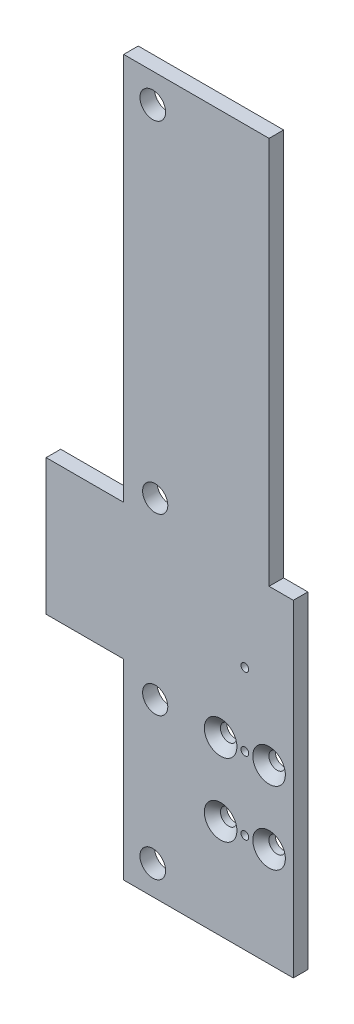
from build123d import *

# Parameters (mm, degrees)
SKETCH1_W                                    = 20
SKETCH1_H                                    = 40
BOSS_EXTRUDE1_DEPTH                          = 3
CSK_FOR_M3_HEX_SOCKET_COUNTERSUNK_CA_2_COUNT = 2
CSK_FOR_M3_HEX_SOCKET_COUNTERSUNK_CA_2_PITCH = 10
CSK_FOR_M3_HEX_SOCKET_COUNTERSUNK_CA_3_COUNT = 2
CSK_FOR_M3_HEX_SOCKET_COUNTERSUNK_CA_3_PITCH = 18.027756377
CSK_FOR_M3_HEX_SOCKET_COUNTERSUNK_CA_4_COUNT = 2
CSK_FOR_M3_HEX_SOCKET_COUNTERSUNK_CA_4_PITCH = 15
M2_TAPPED_HOLE1_D                            = 1.6
BOSS_EXTRUDE2_DEPTH                          = 3
SKETCH7_W                                    = 30
SKETCH7_H                                    = 80.053183591
SKETCH7_R                                    = 2.65
BOSS_EXTRUDE3_DEPTH                          = 3
SKETCH8_R                                    = 2.65
BOSS_EXTRUDE4_DEPTH                          = 3
SKETCH9_R                                    = 2.6
CUT_EXTRUDE1_DEPTH                           = 4


with BuildPart() as part:
    # Sketch1 → Boss-Extrude1 (new body)
    with BuildSketch(Plane.XY):
        Rectangle(SKETCH1_W, SKETCH1_H)
    extrude(amount=BOSS_EXTRUDE1_DEPTH)

    # Sketch3 → CSK for M3 Hex Socket Countersunk Cap Screw1 (revolve, cut)
    with BuildSketch(Plane(origin=(-5, 0, 3), x_dir=(0, -1, 0), z_dir=(1, 0, 0))):
        Polygon((0, 0), (0, 3), (1.7, 3), (1.7, 1.66), (3.36, 0), align=None)
    csk_for_m3_hex_socket_countersunk_cap_sc = revolve(axis=Axis((-5, 0, 9.35), (0, 0, -1)), mode=Mode.SUBTRACT)

    # CSK for M3 Hex Socket Countersunk Ca 2: CSK for M3 Hex Socket Countersunk Cap Screw1 ×2
    with Locations(*[(i * CSK_FOR_M3_HEX_SOCKET_COUNTERSUNK_CA_2_PITCH, 0, 0) for i in range(1, CSK_FOR_M3_HEX_SOCKET_COUNTERSUNK_CA_2_COUNT)]):
        add(csk_for_m3_hex_socket_countersunk_cap_sc, mode=Mode.SUBTRACT)

    # CSK for M3 Hex Socket Countersunk Ca 3: CSK for M3 Hex Socket Countersunk Cap Screw1 ×2
    with Locations(*[Vector(0.554700196, -0.832050294, 0) * (i * CSK_FOR_M3_HEX_SOCKET_COUNTERSUNK_CA_3_PITCH) for i in range(1, CSK_FOR_M3_HEX_SOCKET_COUNTERSUNK_CA_3_COUNT)]):
        add(csk_for_m3_hex_socket_countersunk_cap_sc, mode=Mode.SUBTRACT)

    # CSK for M3 Hex Socket Countersunk Ca 4: CSK for M3 Hex Socket Countersunk Cap Screw1 ×2
    with Locations(*[(0, -i * CSK_FOR_M3_HEX_SOCKET_COUNTERSUNK_CA_4_PITCH, 0) for i in range(1, CSK_FOR_M3_HEX_SOCKET_COUNTERSUNK_CA_4_COUNT)]):
        add(csk_for_m3_hex_socket_countersunk_cap_sc, mode=Mode.SUBTRACT)

    # M2 Tapped Hole1 (through all)
    with Locations(Plane.XY.offset(3)):
        with Locations((0, 15), (0, 0), (0, -15)):
            Hole(M2_TAPPED_HOLE1_D / 2)

    # Sketch6 → Boss-Extrude2 (add)
    with BuildSketch(Plane.XY.offset(3)):
        Polygon((-10, 4), (-41, 4), (-41, 32), (10, 32), (10, 20), (-10, 20), align=None)
    extrude(amount=-BOSS_EXTRUDE2_DEPTH)

    # Sketch7 → Boss-Extrude3 (add)
    with BuildSketch(Plane.XY.offset(3)):
        with Locations((-10, 72.026591795)):
            Rectangle(SKETCH7_W, SKETCH7_H)
        with Locations((-19, 106.053183591)):
            Circle(SKETCH7_R, mode=Mode.SUBTRACT)
    extrude(amount=-BOSS_EXTRUDE3_DEPTH)

    # Sketch8 → Boss-Extrude4 (add)
    with BuildSketch(Plane.XY.offset(3)):
        Polygon((-25, 4), (-25, -35.5), (10, -35.5), (10, -20), (-10, -20), (-10, 4), align=None)
        with Locations((-19, -29.5)):
            Circle(SKETCH8_R, mode=Mode.SUBTRACT)
    extrude(amount=-BOSS_EXTRUDE4_DEPTH)

    # Sketch9 → Cut-Extrude1 (cut, through all)
    with BuildSketch(Plane.XY.offset(3)):
        with Locations((-18.5, 0)):
            Circle(SKETCH9_R)
        with Locations((-18.5, 36)):
            Circle(SKETCH9_R)
    extrude(amount=-CUT_EXTRUDE1_DEPTH, mode=Mode.SUBTRACT)


solid = part.part
